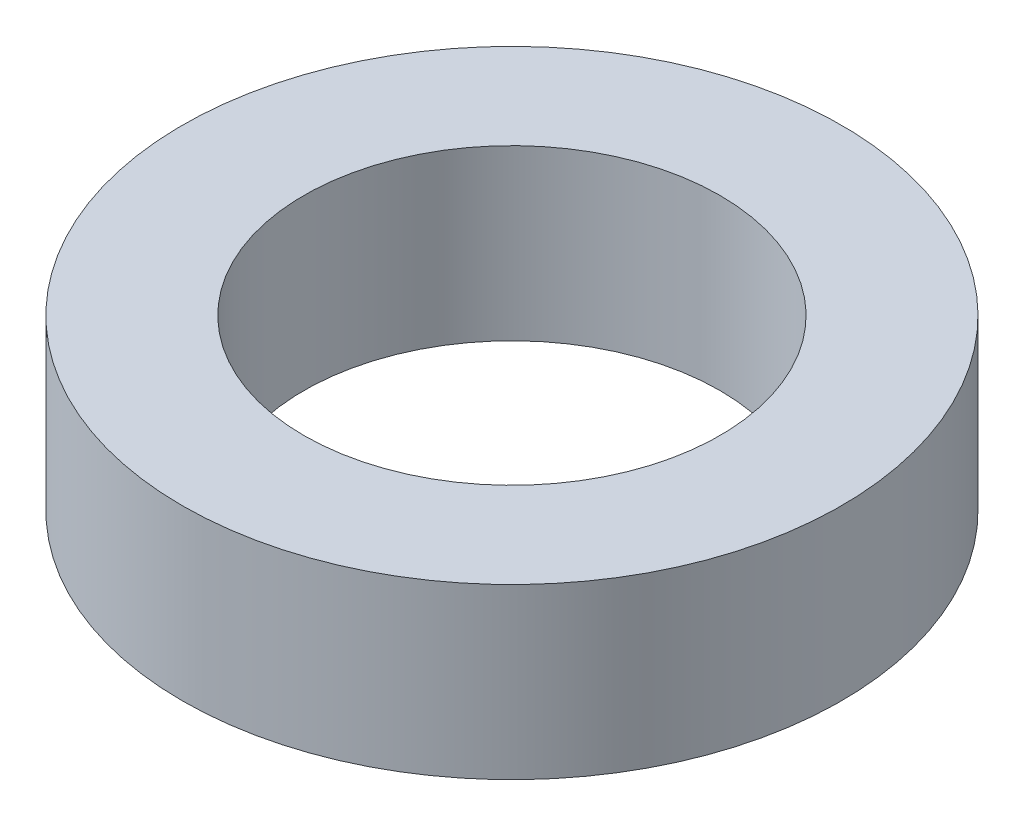
from build123d import *

# Parameters (mm, degrees)
SKETCH1_R           = 25.35
SKETCH1_R_2         = 16
BOSS_EXTRUDE1_DEPTH = 13


with BuildPart() as part:
    # Sketch1 → Boss-Extrude1 (new body)
    with BuildSketch(Plane(origin=(0, 0, 0), x_dir=(1, 0, 0), z_dir=(0, 1, 0))):
        Circle(SKETCH1_R)
        Circle(SKETCH1_R_2, mode=Mode.SUBTRACT)
    extrude(amount=BOSS_EXTRUDE1_DEPTH)


solid = part.part
